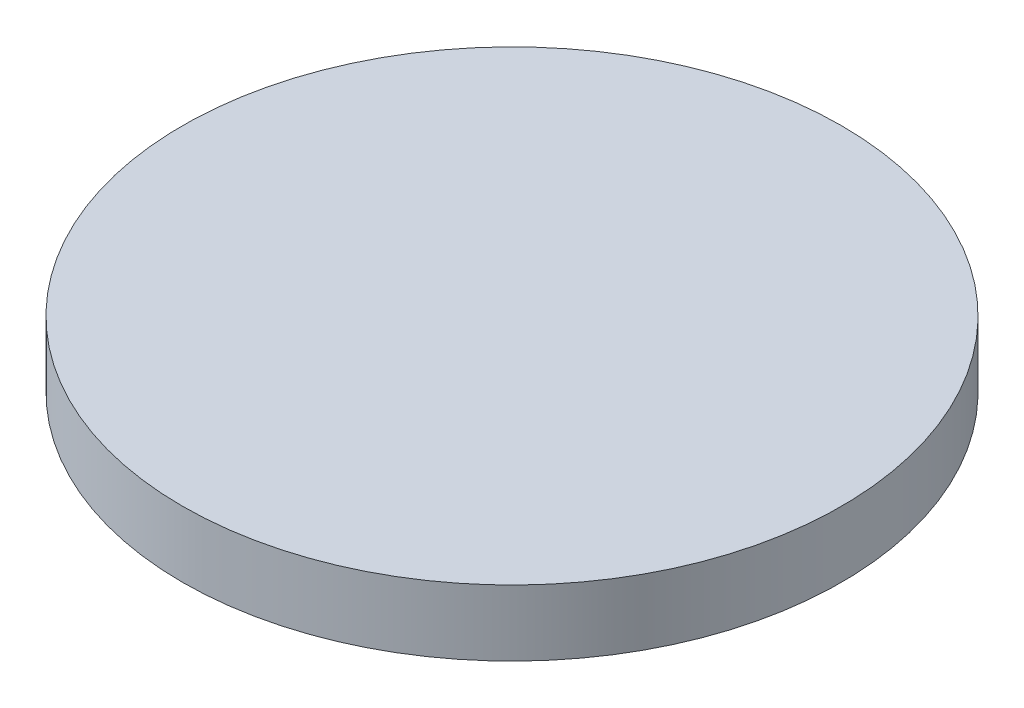
from build123d import *

# Parameters (mm, degrees)
SKETCH1_R           = 5
BOSS_EXTRUDE1_DEPTH = 1


with BuildPart() as part:
    # Sketch1 → Boss-Extrude1 (new body)
    with BuildSketch(Plane(origin=(0, 0, 0), x_dir=(1, 0, 0), z_dir=(0, 1, 0))):
        Circle(SKETCH1_R)
    extrude(amount=BOSS_EXTRUDE1_DEPTH)


solid = part.part
